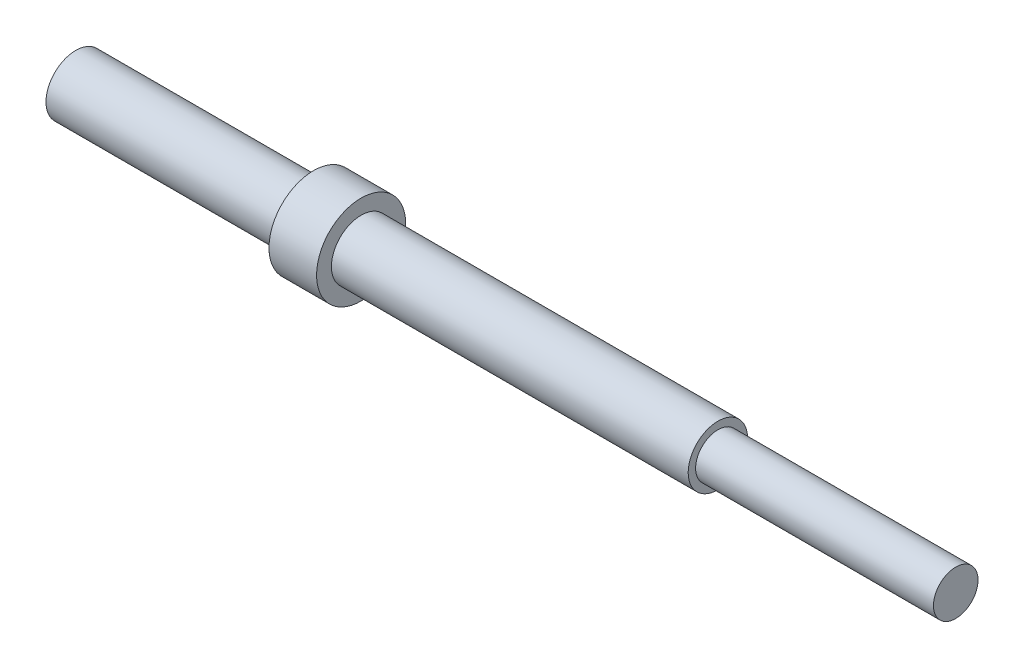
from build123d import *


with BuildPart() as part:
    # Sketch1 → Revolve1 (revolve)
    with BuildSketch(Plane.XY):
        Polygon((0, 1.905), (38.1, 1.905), (38.1, 0), (93.98, 0), (93.98, 2.38125), (68.58, 2.38125), (68.58, 3.175), (30.48, 3.175), (30.48, 4.7625), (25.4, 4.7625), (25.4, 3.175), (0, 3.175), align=None)
    revolve(axis=Axis((0, 0, 0), (1, 0, 0)))


solid = part.part
